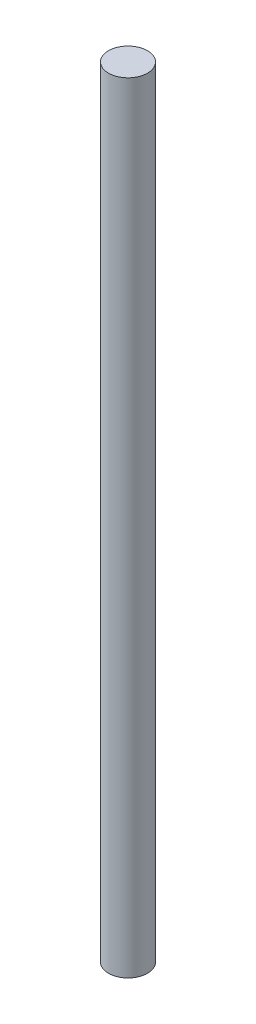
from build123d import *

# Parameters (mm, degrees)
SKETCH_1_R      = 1
EXTRUDE_2_DEPTH = 40


with BuildPart() as part:
    # 草图1 → 凸台-拉伸2 (new body)
    with BuildSketch(Plane(origin=(0, 0, 0), x_dir=(1, 0, 0), z_dir=(0, 1, 0))):
        Circle(SKETCH_1_R)
    extrude(amount=EXTRUDE_2_DEPTH)


solid = part.part
